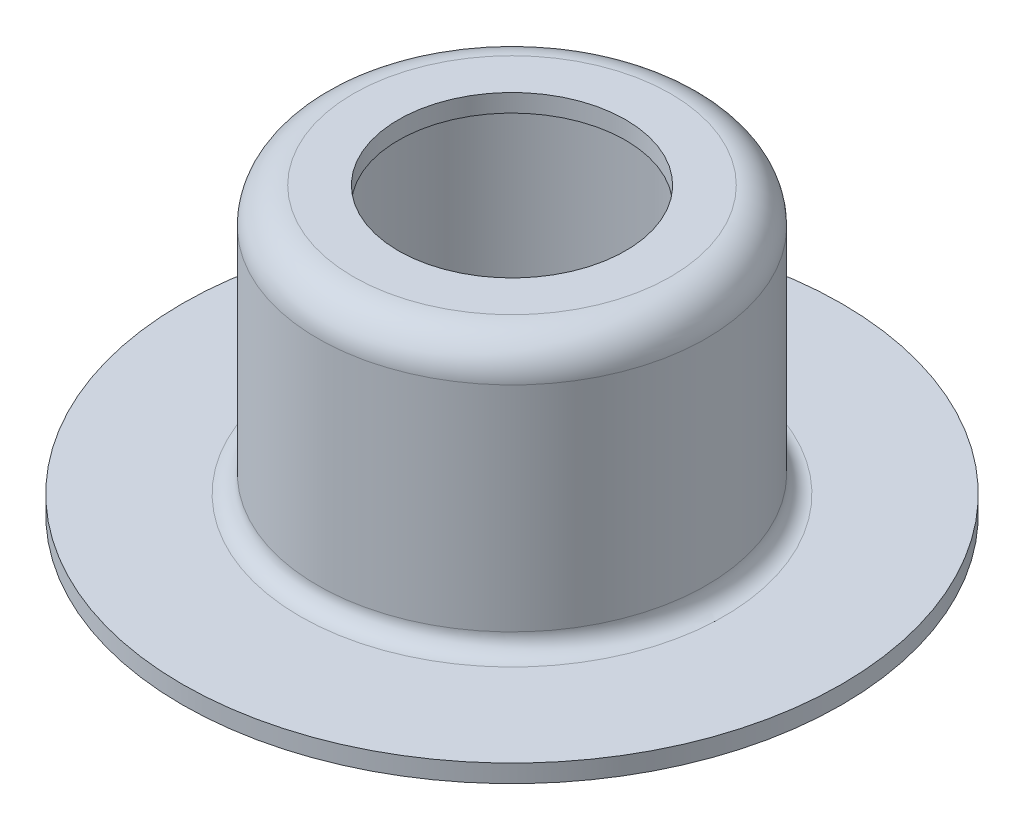
from build123d import *


with BuildPart() as part:
    # Sketch1 → Revolve1 (revolve)
    with BuildSketch(Plane.XY):
        with BuildLine():
            Line((-18.5, 0), (-10.9, 0))
            ThreePointArc((-10.9, 0), (-9.485786438, 0.585786438), (-8.9, 2))
            Line((-8.9, 2), (-8.9, 14))
            ThreePointArc((-8.9, 14), (-8.607106781, 14.707106781), (-7.9, 15))
            Line((-7.9, 15), (-6.375, 15))
            Line((-6.375, 15), (-6.375, 16))
            Line((-6.375, 16), (-8.9, 16))
            ThreePointArc((-8.9, 16), (-10.314213562, 15.414213562), (-10.9, 14))
            Line((-10.9, 14), (-10.9, 2))
            ThreePointArc((-10.9, 2), (-11.192893219, 1.292893219), (-11.9, 1))
            Line((-11.9, 1), (-18.5, 1))
            Line((-18.5, 1), (-18.5, 0))
        make_face()
    revolve(axis=Axis((0, 0, 0), (0, 1, 0)))


solid = part.part
